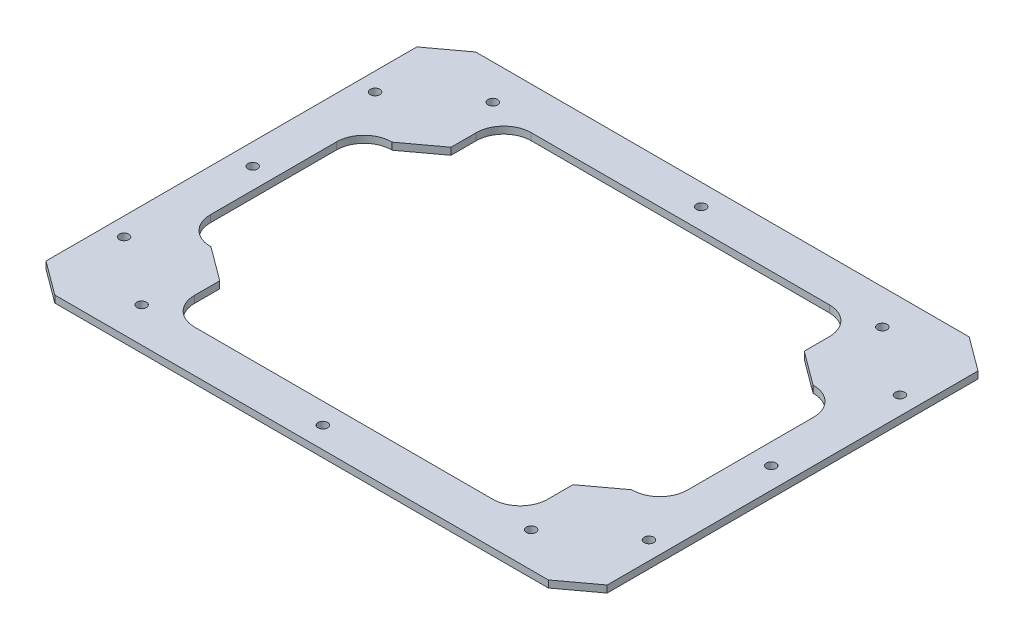
from build123d import *

# Parameters (mm, degrees)
BOSS_EXTRUDE1_DEPTH = 3.175
SKETCH2_R           = 2.159
CUT_EXTRUDE1_DEPTH  = 4.175


with BuildPart() as part:
    # Sketch1 → Boss-Extrude1 (new body)
    with BuildSketch(Plane(origin=(0, 0, 0), x_dir=(1, 0, 0), z_dir=(0, 1, 0))):
        Polygon((-111.686526805, 95.25), (-127, 83.918625912), (-127, -83.918625912), (-111.686526805, -95.25), (111.686526805, -95.25), (127, -83.918625912), (127, 83.918625912), (111.686526805, 95.25), align=None)
        with BuildLine():
            Line((-107.95, -28.564963508), (-107.95, 28.564963508))
            ThreePointArc((-107.95, 28.564963508), (-104.304650999, 37.365614506), (-95.504, 41.010963508))
            Line((-95.504, 41.010963508), (-95.25, 41.010963508))
            Line((-95.25, 41.010963508), (-79.936526805, 52.342337595))
            Line((-79.936526805, 52.342337595), (-79.936526805, 63.754))
            ThreePointArc((-79.936526805, 63.754), (-76.291177804, 72.554650999), (-67.490526805, 76.2))
            Line((-67.490526805, 76.2), (38.831798823, 76.2))
            Line((38.831798823, 76.2), (67.490526805, 76.2))
            ThreePointArc((67.490526805, 76.2), (76.291177804, 72.554650999), (79.936526805, 63.754))
            Line((79.936526805, 63.754), (79.936526805, 52.342337595))
            Line((79.936526805, 52.342337595), (95.25, 41.010963508))
            Line((95.25, 41.010963508), (95.504, 41.010963508))
            ThreePointArc((95.504, 41.010963508), (104.304650999, 37.365614506), (107.95, 28.564963508))
            Line((107.95, 28.564963508), (107.95, -28.564963508))
            ThreePointArc((107.95, -28.564963508), (104.304650999, -37.365614506), (95.504, -41.010963508))
            Line((95.504, -41.010963508), (95.25, -41.010963508))
            Line((95.25, -41.010963508), (79.936526805, -52.342337595))
            Line((79.936526805, -52.342337595), (79.936526805, -63.754))
            ThreePointArc((79.936526805, -63.754), (76.291177804, -72.554650999), (67.490526805, -76.2))
            Line((67.490526805, -76.2), (38.1, -76.2))
            Line((38.1, -76.2), (-67.490526805, -76.2))
            ThreePointArc((-67.490526805, -76.2), (-76.291177804, -72.554650999), (-79.936526805, -63.754))
            Line((-79.936526805, -63.754), (-79.936526805, -52.342337595))
            Line((-79.936526805, -52.342337595), (-95.25, -41.010963508))
            Line((-95.25, -41.010963508), (-95.504, -41.010963508))
            ThreePointArc((-95.504, -41.010963508), (-104.304650999, -37.365614506), (-107.95, -28.564963508))
        make_face(mode=Mode.SUBTRACT)
    extrude(amount=BOSS_EXTRUDE1_DEPTH)

    # Sketch2 → Cut-Extrude1 (cut, through all)
    with BuildSketch(Plane(origin=(0, 3.175, 0), x_dir=(1, 0, 0), z_dir=(0, 1, 0))):
        with Locations((-88.154790208, 79.461855841)):
            Circle(SKETCH2_R)
        with Locations((88.154790208, 79.461855841)):
            Circle(SKETCH2_R)
        with Locations((88.154790208, -79.461855841)):
            Circle(SKETCH2_R)
        with Locations((-88.154790208, -79.461855841)):
            Circle(SKETCH2_R)
        with Locations((-118.781736597, 56.799107666)):
            Circle(SKETCH2_R)
        with Locations((118.781736597, 56.799107666)):
            Circle(SKETCH2_R)
        with Locations((-118.781736597, -56.799107666)):
            Circle(SKETCH2_R)
        with Locations((118.781736597, -56.799107666)):
            Circle(SKETCH2_R)
        with Locations((0, -85.598)):
            Circle(SKETCH2_R)
        with Locations((0, 85.598)):
            Circle(SKETCH2_R)
        with Locations((-117.348, -0.020516524)):
            Circle(SKETCH2_R)
        with Locations((117.348, -0.020516524)):
            Circle(SKETCH2_R)
    extrude(amount=-CUT_EXTRUDE1_DEPTH, mode=Mode.SUBTRACT)


solid = part.part
